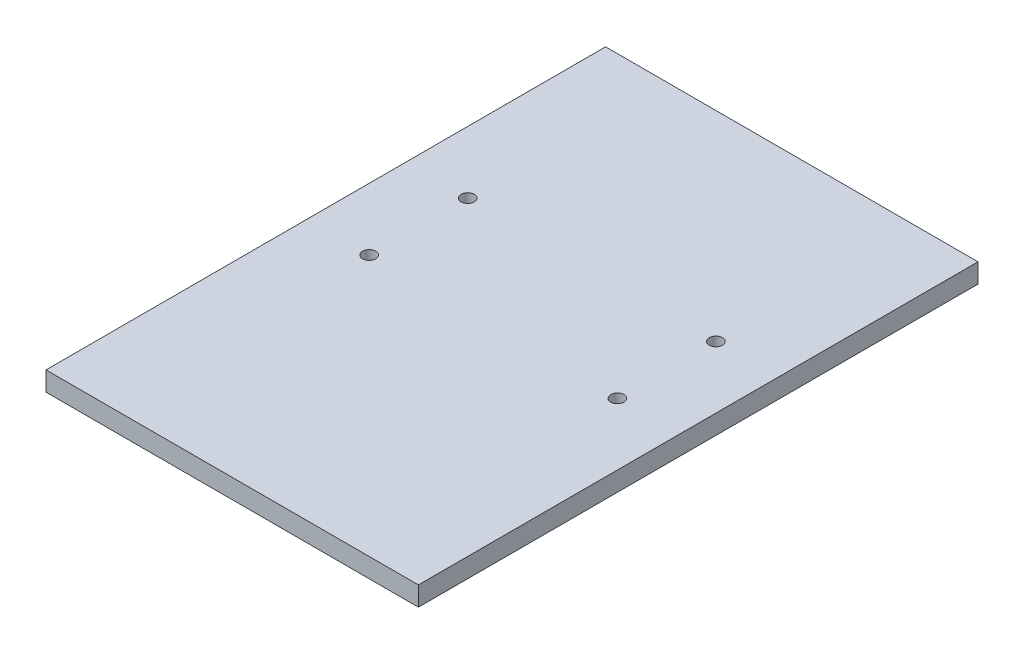
from build123d import *

# Parameters (mm, degrees)
SKETCH1_W              = 240.03
SKETCH1_H              = 360.68
BOSS_EXTRUDE1_DEPTH    = 12.446
M10X1_5_TAPPED_HOLE1_D = 8.5


with BuildPart() as part:
    # Sketch1 → Boss-Extrude1 (new body)
    with BuildSketch(Plane(origin=(0, 0, 0), x_dir=(1, 0, 0), z_dir=(0, 1, 0))):
        Rectangle(SKETCH1_W, SKETCH1_H)
    extrude(amount=BOSS_EXTRUDE1_DEPTH)

    # M10x1.5 Tapped Hole1 (through all)
    with Locations(Plane(origin=(0, 12.446, 0), x_dir=(1, 0, 0), z_dir=(0, 1, 0))):
        with Locations((80.01, 51.435), (80.01, -12.065)):
            m10x1_5_tapped_hole1 = Hole(M10X1_5_TAPPED_HOLE1_D / 2)

    # Mirror1: M10x1.5 Tapped Hole1 across plane
    add(m10x1_5_tapped_hole1.mirror(Plane.ZY), mode=Mode.SUBTRACT)


solid = part.part
